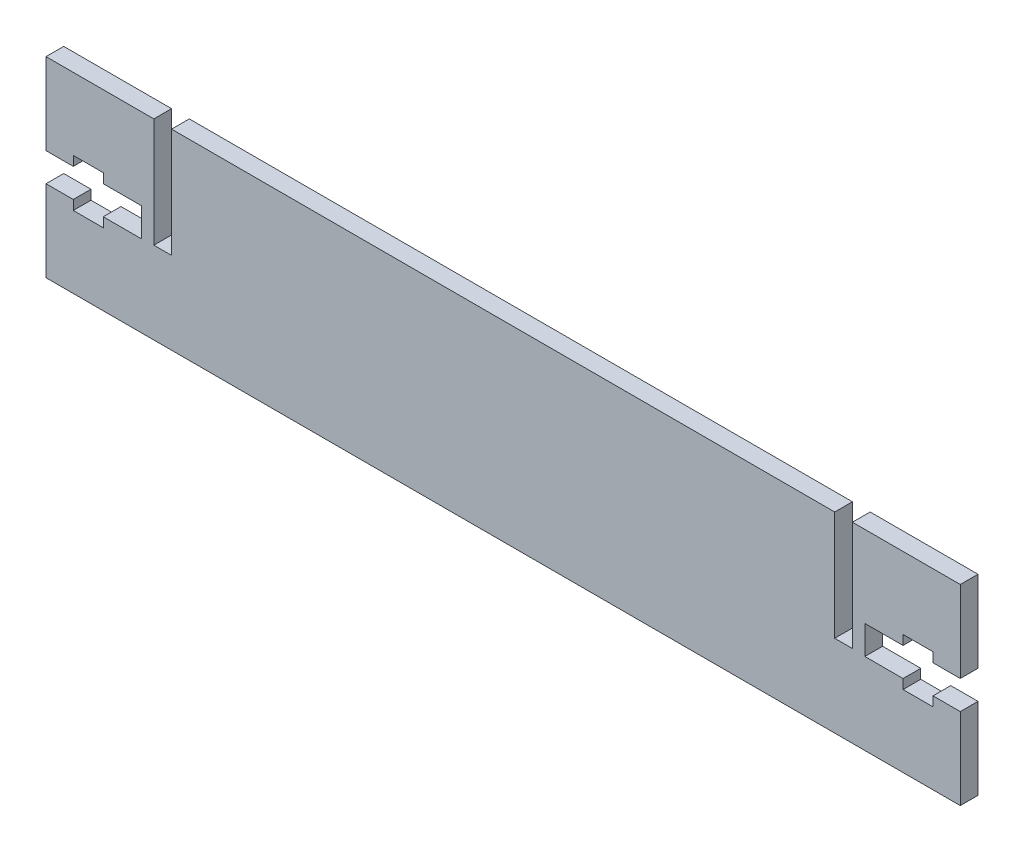
from build123d import *

# Parameters (mm, degrees)
BOSS_EXTRUDE1_DEPTH = 1.651
CUT_EXTRUDE1_DEPTH  = 4.302


with BuildPart() as part:
    # Sketch1 → Boss-Extrude1 (new body, symmetric)
    with BuildSketch(Plane.XY):
        Polygon((85.181948, -17.8435), (85.181948, 17.8435), (65.084948, 17.8435), (65.084948, -2.54), (61.782948, -2.54), (61.782948, 17.8435), (-61.782948, 17.8435), (-61.782948, -2.54), (-65.084948, -2.54), (-65.084948, 17.8435), (-85.181948, 17.8435), (-85.181948, -17.8435), align=None)
    extrude(amount=BOSS_EXTRUDE1_DEPTH, both=True)

    # Sketch2 → Cut-Extrude1 (cut, through all)
    with BuildSketch(Plane.XY.offset(1.651)):
        Polygon((85.181948, 2.667), (80.101948, 2.667), (80.101948, 4.445), (74.513948, 4.445), (74.513948, 2.667), (67.401948, 2.667), (67.401948, -2.667), (74.513948, -2.667), (74.513948, -4.445), (80.101948, -4.445), (80.101948, -2.667), (85.181948, -2.667), align=None)
        Polygon((-85.181948, -2.667), (-80.101948, -2.667), (-80.101948, -4.445), (-74.513948, -4.445), (-74.513948, -2.667), (-67.401948, -2.667), (-67.401948, 2.667), (-74.513948, 2.667), (-74.513948, 4.445), (-80.101948, 4.445), (-80.101948, 2.667), (-85.181948, 2.667), align=None)
    extrude(amount=-CUT_EXTRUDE1_DEPTH, mode=Mode.SUBTRACT)


solid = part.part
